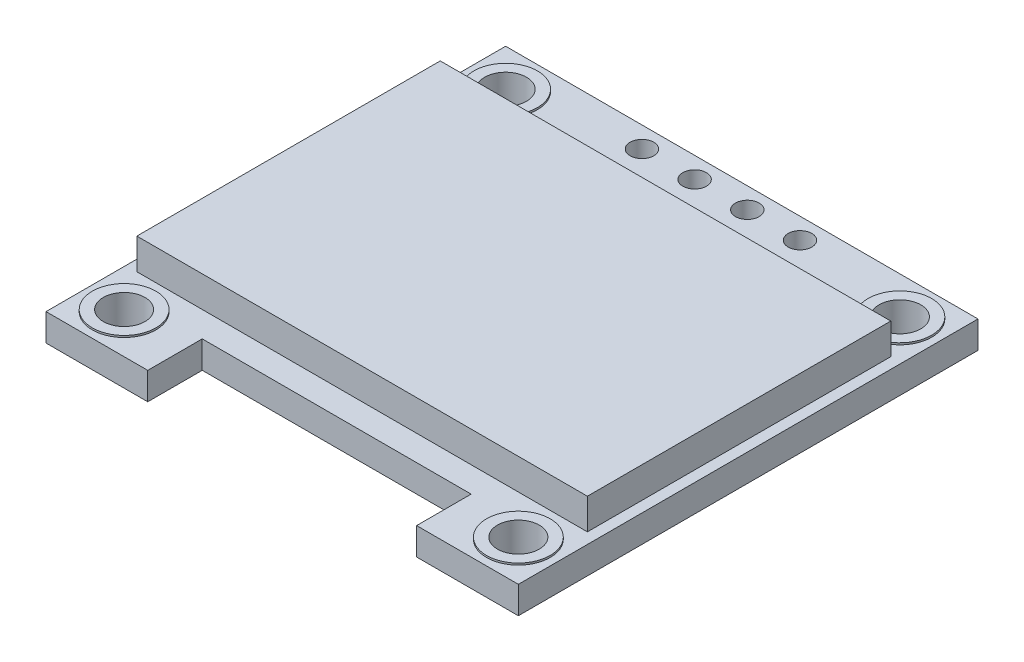
from build123d import *

# Parameters (mm, degrees)
SKETCH1_W                = 26
SKETCH1_H                = 25.3
BOSS_EXTRUDE1_DEPTH      = 1.5
SKETCH2_W                = 14.8
SKETCH2_H                = 3
CUT_EXTRUDE1_DEPTH       = 1.5
SKETCH3_R                = 1.15
CUT_EXTRUDE2_DEPTH       = 1.5
SKETCH4_R                = 1.75
SKETCH4_R_2              = 1.15
BOSS_EXTRUDE3_DEPTH      = 0.1
BOSS_EXTRUDE3_DEPTH_BACK = 1.6
SKETCH6_W                = 24.8
SKETCH6_H                = 16.7
BOSS_EXTRUDE4_DEPTH      = 1.7
SKETCH7_W                = 21.1
SKETCH7_H                = 3.3
SKETCH7_W_2              = 12.9
BOSS_EXTRUDE5_DEPTH      = 0.8
SKETCH8_R                = 0.65
CUT_EXTRUDE4_DEPTH       = 4.2


with BuildPart() as part:
    # Sketch1 → Boss-Extrude1 (new body)
    with BuildSketch(Plane(origin=(0, 0, 0), x_dir=(1, 0, 0), z_dir=(0, 1, 0))):
        with Locations((2.394736842, -5.260526316)):
            Rectangle(SKETCH1_W, SKETCH1_H)
    extrude(amount=BOSS_EXTRUDE1_DEPTH)

    # Sketch2 → Cut-Extrude1 (cut)
    with BuildSketch(Plane(origin=(0, 1.5, 0), x_dir=(1, 0, 0), z_dir=(0, 1, 0))):
        with Locations((2.394736842, -16.410526316)):
            Rectangle(SKETCH2_W, SKETCH2_H)
    extrude(amount=-CUT_EXTRUDE1_DEPTH, mode=Mode.SUBTRACT)

    # Sketch3 → Cut-Extrude2 (cut)
    with BuildSketch(Plane(origin=(0, 1.5, 0), x_dir=(1, 0, 0), z_dir=(0, 1, 0))):
        with Locations((-8.455263158, 5.239473684)):
            Circle(SKETCH3_R)
        with Locations((13.244736842, 5.239473684)):
            Circle(SKETCH3_R)
        with Locations((13.244736842, -15.760526316)):
            Circle(SKETCH3_R)
        with Locations((-8.455263158, -15.760526316)):
            Circle(SKETCH3_R)
    extrude(amount=-CUT_EXTRUDE2_DEPTH, mode=Mode.SUBTRACT)

    # Sketch4 → Boss-Extrude3 (add, two sides)
    with BuildSketch(Plane(origin=(0, 1.5, 0), x_dir=(1, 0, 0), z_dir=(0, 1, 0))) as boss_extrude3_sk:
        with Locations((-8.455263158, 5.239473684)):
            Circle(SKETCH4_R)
        with Locations((-8.455263158, 5.239473684)):
            Circle(SKETCH4_R_2, mode=Mode.SUBTRACT)
        with Locations((13.244736842, 5.239473684)):
            Circle(SKETCH4_R)
        with Locations((13.244736842, 5.239473684)):
            Circle(SKETCH4_R_2, mode=Mode.SUBTRACT)
        with Locations((13.244736842, -15.760526316)):
            Circle(SKETCH4_R)
        with Locations((13.244736842, -15.760526316)):
            Circle(SKETCH4_R_2, mode=Mode.SUBTRACT)
        with Locations((-8.455263158, -15.760526316)):
            Circle(SKETCH4_R)
        with Locations((-8.455263158, -15.760526316)):
            Circle(SKETCH4_R_2, mode=Mode.SUBTRACT)
    extrude(amount=BOSS_EXTRUDE3_DEPTH)
    extrude(boss_extrude3_sk.sketch, amount=-BOSS_EXTRUDE3_DEPTH_BACK)

    # Sketch6 → Boss-Extrude4 (add)
    with BuildSketch(Plane(origin=(0, 1.5, 0), x_dir=(1, 0, 0), z_dir=(0, 1, 0))):
        with Locations((2.394736842, -5.160526316)):
            Rectangle(SKETCH6_W, SKETCH6_H)
    extrude(amount=BOSS_EXTRUDE4_DEPTH)

    # Sketch7 → Boss-Extrude5 (add)
    with BuildSketch(Plane.XZ):
        with Locations((2.394736842, 3.960526316)):
            Rectangle(SKETCH7_W, SKETCH7_H)
        with Locations((3.144736842, -2.039473684)):
            Rectangle(SKETCH7_W_2, SKETCH7_H)
    extrude(amount=BOSS_EXTRUDE5_DEPTH)

    # Sketch8 → Cut-Extrude4 (cut, through all)
    with BuildSketch(Plane.XZ):
        with Locations((-1.955263158, -6.241133994)):
            Circle(SKETCH8_R)
        with Locations((0.944736842, -6.241133994)):
            Circle(SKETCH8_R)
        with Locations((3.844736842, -6.241133994)):
            Circle(SKETCH8_R)
        with Locations((6.744736842, -6.241133994)):
            Circle(SKETCH8_R)
    extrude(amount=-CUT_EXTRUDE4_DEPTH, mode=Mode.SUBTRACT)


solid = part.part
